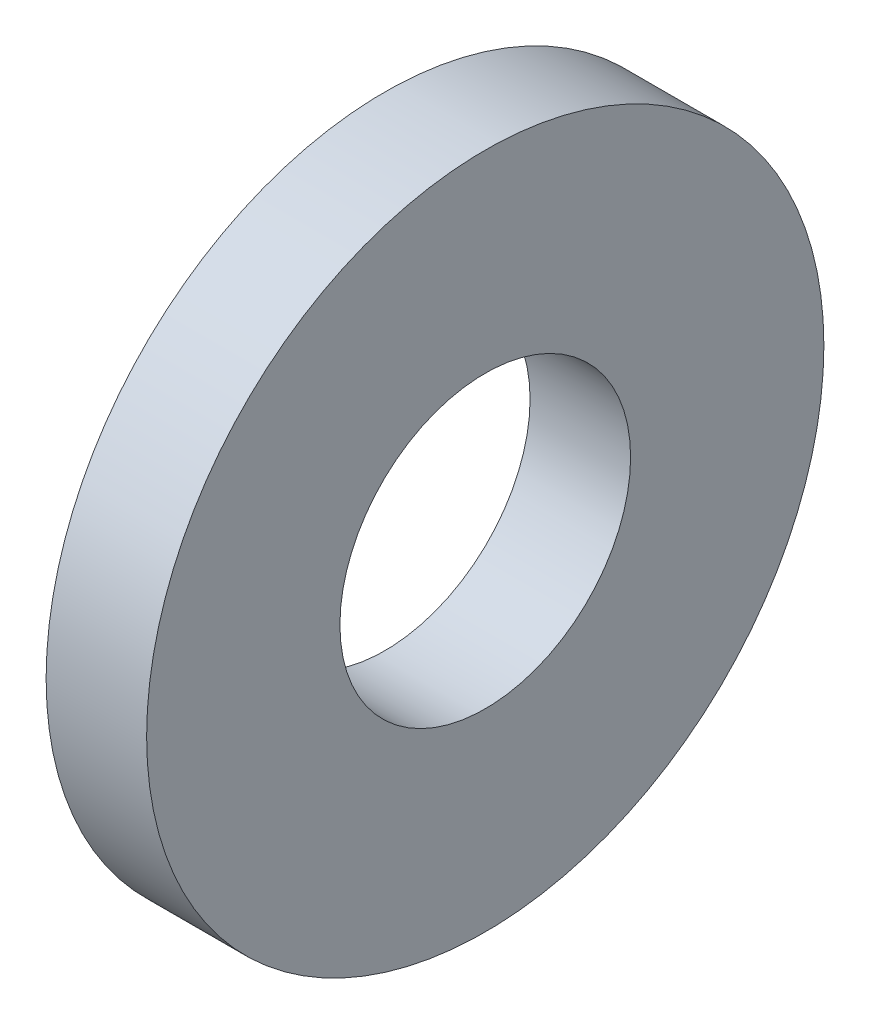
from build123d import *

# Parameters (mm, degrees)
SKETCH1_R           = 5.5626
SKETCH1_R_2         = 2.3876
BOSS_EXTRUDE1_DEPTH = 1.651


with BuildPart() as part:
    # Sketch1 → Boss-Extrude1 (new body)
    with BuildSketch(Plane(origin=(0, 0, 0), x_dir=(0, 0, -1), z_dir=(1, 0, 0))):
        Circle(SKETCH1_R)
        Circle(SKETCH1_R_2, mode=Mode.SUBTRACT)
    extrude(amount=BOSS_EXTRUDE1_DEPTH)


solid = part.part
